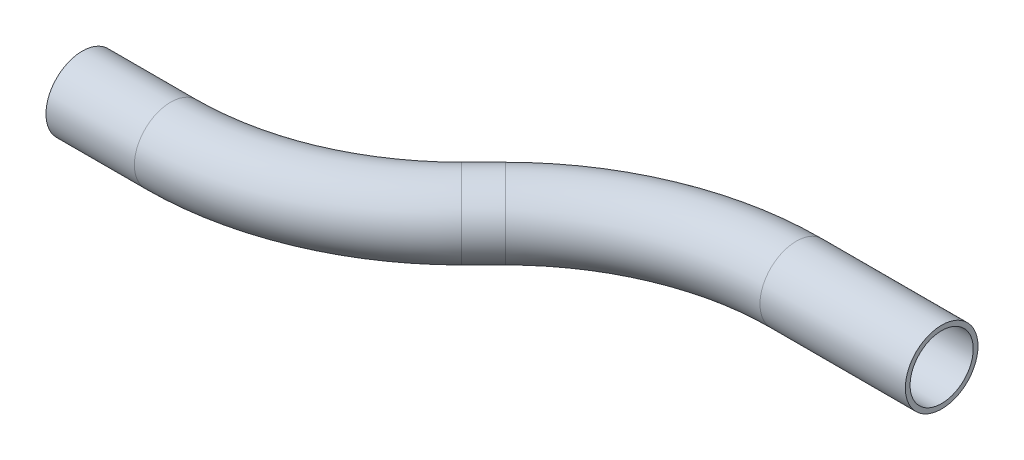
from build123d import *

# Parameters (mm, degrees)
SKETCH2_R   = 9.525
SKETCH2_R_2 = 8.2804


with BuildPart() as part:
    # Sweep1: sweep along a path in Sketch1
    with BuildLine(Plane(origin=(0, 0, 0), x_dir=(1, 0, 0), z_dir=(0, 1, 0))) as sweep1_path:
        Line((0, 0), (23.175584151, 0))
        ThreePointArc((23.175584151, 0), (52.336061697, 5.800379623), (77.057120878, 22.318463274))
        Line((77.057120878, 22.318463274), (82.83632413, 28.097666526))
        ThreePointArc((82.83632413, 28.097666526), (107.557383311, 44.615750177), (136.717860857, 50.4161298))
        Line((136.717860857, 50.4161298), (174.817860857, 50.4161298))
    # Sketch2 → Sweep1 (sweep)
    with BuildSketch(Plane(origin=(0, 0, 0), x_dir=(0, 0, -1), z_dir=(1, 0, 0))):
        Circle(SKETCH2_R)
        Circle(SKETCH2_R_2, mode=Mode.SUBTRACT)
    sweep(path=sweep1_path.line)


solid = part.part
